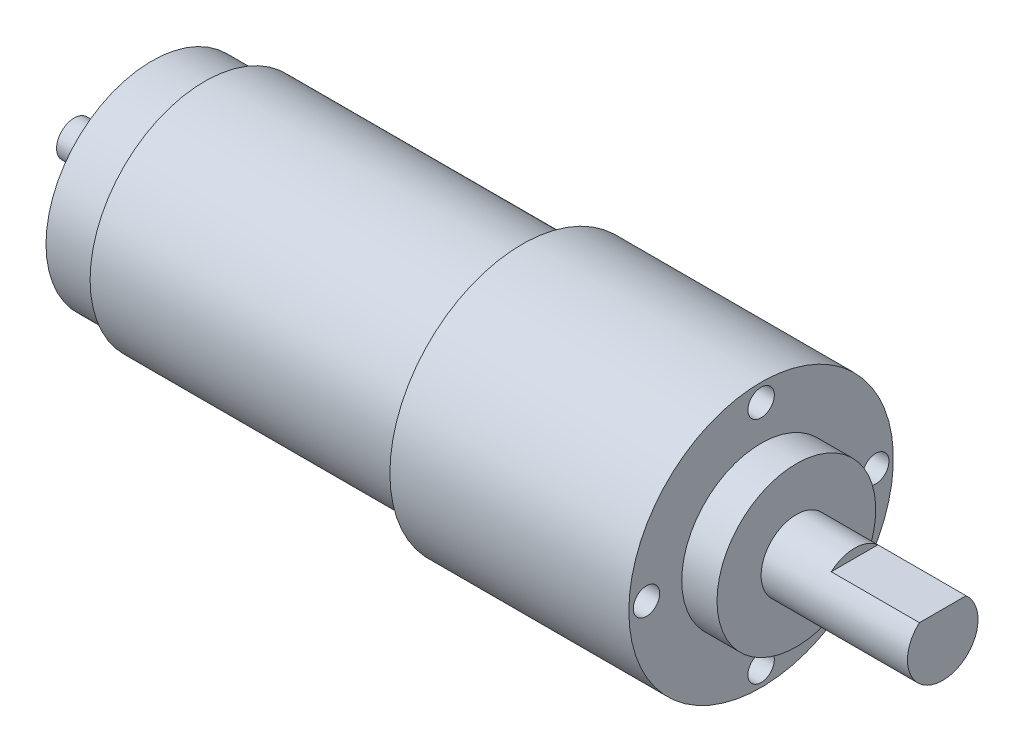
from build123d import *

# Parameters (mm, degrees)
ESQUISSE2_W             = 5.291502622
ESQUISSE2_H             = 1
ENL_V_MAT_EXTRU_1_DEPTH = 10
ESQUISSE3_R             = 1.5
FIXHOLES_DEPTH          = 3
REPEATFIXHOLES_COUNT    = 4


with BuildPart() as part:
    # Esquisse1 → MainRevolution (revolve)
    with BuildSketch(Plane.XY):
        Polygon((0, 0), (98.5, 0), (98.5, 4), (81.9, 4), (81.9, 9), (77.9, 9), (77.9, 15), (50.8, 15), (50.8, 13), (14.8, 13), (14.8, 12), (8.8, 12), (8.8, 2), (0, 2), align=None)
    revolve(axis=Axis((0, 0, 0), (1, 0, 0)))

    # Esquisse2 → Enlèv. mat.-Extru.1 (cut)
    with BuildSketch(Plane(origin=(98.5, 0, 0), x_dir=(0, 0, -1), z_dir=(1, 0, 0))):
        with Locations((0, 3.5)):
            Rectangle(ESQUISSE2_W, ESQUISSE2_H)
    extrude(amount=-ENL_V_MAT_EXTRU_1_DEPTH, mode=Mode.SUBTRACT)

    # Esquisse3 → FixHoles (cut)
    with BuildSketch(Plane(origin=(77.9, 0, 0), x_dir=(0, 0, -1), z_dir=(1, 0, 0))):
        with Locations((0, 13)):
            Circle(ESQUISSE3_R)
    fixholes = extrude(amount=-FIXHOLES_DEPTH, mode=Mode.SUBTRACT)

    # RepeatFixHoles: FixHoles ×4 about axis
    repeatfixholes_axis = Axis((-5.325, 0, 0), (1, 0, 0))
    for i in range(1, REPEATFIXHOLES_COUNT):
        add(fixholes.rotate(repeatfixholes_axis, i * 360 / REPEATFIXHOLES_COUNT), mode=Mode.SUBTRACT)


solid = part.part
